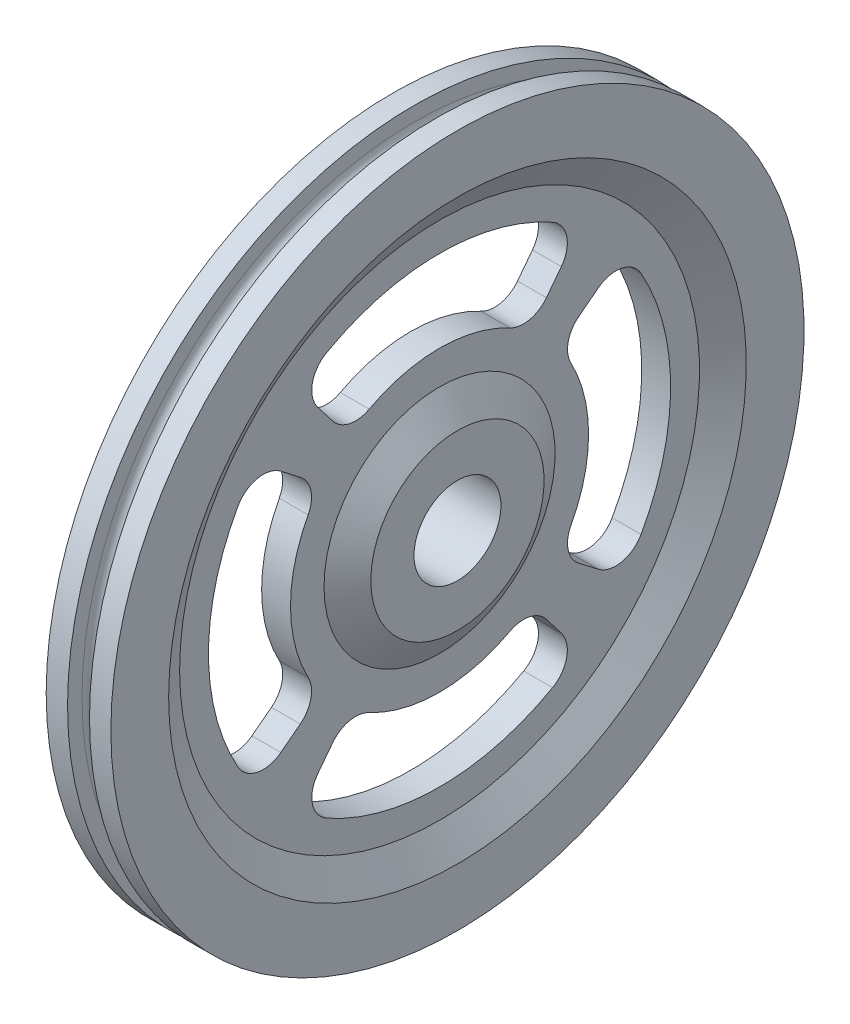
from build123d import *

# Parameters (mm, degrees)
CUT_EXTRUDE1_DEPTH = 6.35
CIRPATTERN1_COUNT  = 4


with BuildPart() as part:
    # Sketch1 → Revolve1 (revolve)
    with BuildSketch(Plane.XY):
        with BuildLine():
            Line((-7.112, 19.05), (-3.175, 25.4))
            Line((-3.175, 25.4), (-3.175, 57.15))
            Line((-3.175, 57.15), (-7.112, 63.5))
            Line((-7.112, 63.5), (-7.112, 76.2))
            Line((-7.112, 76.2), (-2.413, 76.2))
            Line((-2.413, 76.2), (-2.413, 73.025))
            ThreePointArc((-2.413, 73.025), (0, 70.612), (2.413, 73.025))
            Line((2.413, 73.025), (2.413, 76.2))
            Line((2.413, 76.2), (7.112, 76.2))
            Line((7.112, 76.2), (7.112, 63.5))
            Line((7.112, 63.5), (3.175, 57.15))
            Line((3.175, 57.15), (3.175, 25.4))
            Line((3.175, 25.4), (7.112, 19.05))
            Line((7.112, 19.05), (7.112, 9.55675))
            Line((7.112, 9.55675), (-7.112, 9.55675))
            Line((-7.112, 9.55675), (-7.112, 19.05))
        make_face()
    revolve(axis=Axis((0, 0, 0), (1, 0, 0)))

    # Sketch2 → Cut-Extrude1 (cut)
    with BuildSketch(Plane(origin=(3.175, 0, 0), x_dir=(0, 0, -1), z_dir=(1, 0, 0))):
        with BuildLine():
            Line((23.49644805, 30.621167271), (26.781905408, 34.902858661))
            ThreePointArc((26.781905408, 34.902858661), (27.96426729, 40.046055634), (24.850413368, 44.306849983))
            ThreePointArc((24.850413368, 44.306849983), (0, 50.8), (-24.850413368, 44.306849983))
            ThreePointArc((-24.850413368, 44.306849983), (-27.96426729, 40.046055634), (-26.781905408, 34.902858661))
            Line((-26.781905408, 34.902858661), (-23.49644805, 30.621167271))
            ThreePointArc((-23.49644805, 30.621167271), (-19.797458156, 28.279540119), (-15.462119544, 28.888295471))
            ThreePointArc((-15.462119544, 28.888295471), (0, 32.766), (15.462119544, 28.888295471))
            ThreePointArc((15.462119544, 28.888295471), (19.797458156, 28.279540119), (23.49644805, 30.621167271))
        make_face()
    cut_extrude1 = extrude(amount=-CUT_EXTRUDE1_DEPTH, mode=Mode.SUBTRACT)

    # CirPattern1: Cut-Extrude1 ×4 about axis
    cirpattern1_axis = Axis((0, 0, 0), (1, 0, 0))
    for i in range(1, CIRPATTERN1_COUNT):
        add(cut_extrude1.rotate(cirpattern1_axis, i * 360 / CIRPATTERN1_COUNT), mode=Mode.SUBTRACT)


solid = part.part
